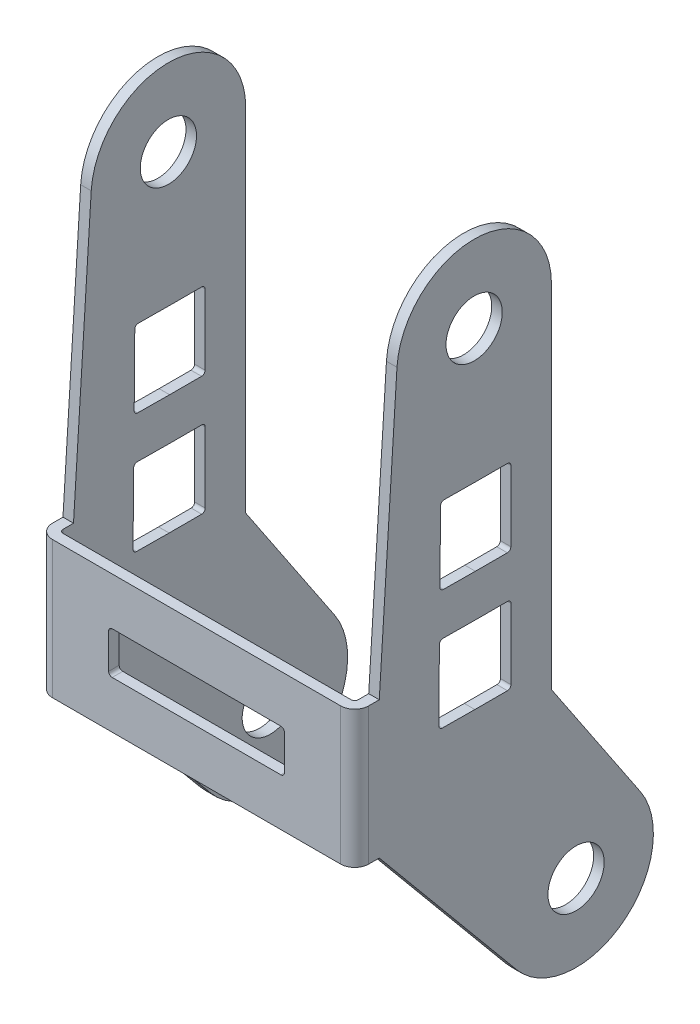
from build123d import *

# Parameters (mm, degrees)
BOSS_EXTRUDE1_DEPTH          = 1.5
SKETCH2_W                    = 43.5
SKETCH2_H                    = 19.5
BOSS_EXTRUDE2_DEPTH          = 3.5
SKETCH3_W                    = 42
SKETCH3_H                    = 19.5
CUT_EXTRUDE1_DEPTH           = 2
BOSS_EXTRUDE3_DEPTH          = 1.5
F_8_0_8_DIAMETER_HOLE1_D     = 8
F_8_0_8_DIAMETER_HOLE1_DEPTH = 1.5
F_8_0_8_DIAMETER_HOLE2_D     = 8
F_8_0_8_DIAMETER_HOLE2_DEPTH = 1.5
FILLET1_R                    = 0.5
FILLET2_R                    = 2
SKETCH9_W                    = 25
SKETCH9_H                    = 6
CUT_EXTRUDE2_DEPTH           = 1.5
FILLET3_R                    = 0.5
CUT_EXTRUDE3_DEPTH           = 45
FILLET4_R                    = 0.5


with BuildPart() as part:
    # Sketch1 → Boss-Extrude1 (new body)
    with BuildSketch(Plane(origin=(-22.5, 0, 0), x_dir=(0, -1, 0), z_dir=(-1, 0, 0))):
        with BuildLine():
            Line((82.02741971, -6.037413385), (58.5, 13.5))
            Line((58.5, 13.5), (39, 13.5))
            Line((39, 13.5), (-0.697466415, 10.97786594))
            ThreePointArc((-0.697466415, 10.97786594), (-10.994465093, -0.348908769), (0, -11))
            Line((0, -11), (50, -11))
            Line((50, -11), (68.880323706, -23.640544954))
            ThreePointArc((68.880323706, -23.640544954), (83.813260452, -21.082282295), (82.02741971, -6.037413385))
        make_face()
    extrude(amount=-BOSS_EXTRUDE1_DEPTH)

    # Sketch2 → Boss-Extrude2 (add)
    with BuildSketch(Plane.XY.offset(13.5)):
        with Locations((-0.75, -48.75)):
            Rectangle(SKETCH2_W, SKETCH2_H)
    extrude(amount=BOSS_EXTRUDE2_DEPTH)

    # Sketch3 → Cut-Extrude1 (cut)
    with BuildSketch(Plane(origin=(0, 0, 13.5), x_dir=(-1, 0, 0), z_dir=(0, 0, -1))):
        with Locations((0, -48.75)):
            Rectangle(SKETCH3_W, SKETCH3_H)
    extrude(amount=-CUT_EXTRUDE1_DEPTH, mode=Mode.SUBTRACT)

    # Sketch4 → Boss-Extrude3 (add)
    with BuildSketch(Plane(origin=(21, 0, 0), x_dir=(0, 0, -1), z_dir=(1, 0, 0))):
        with BuildLine():
            Line((11, 0), (11, -50))
            Line((11, -50), (23.640544954, -68.880323706))
            ThreePointArc((23.640544954, -68.880323706), (21.082282295, -83.813260452), (6.037413385, -82.02741971))
            Line((6.037413385, -82.02741971), (-13.5, -58.5))
            Line((-13.5, -58.5), (-17, -58.5))
            Line((-17, -58.5), (-17, -39))
            Line((-17, -39), (-13.5, -39))
            Line((-13.5, -39), (-10.97786594, 0.697466415))
            ThreePointArc((-10.97786594, 0.697466415), (0.348908769, 10.994465093), (11, 0))
        make_face()
    extrude(amount=BOSS_EXTRUDE3_DEPTH)

    # Ø8.0 (8) Diameter Hole1
    with Locations(Plane.ZY.offset(-21)):
        with Locations((-14.5, -75), (0, 0)):
            Hole(F_8_0_8_DIAMETER_HOLE1_D / 2, depth=F_8_0_8_DIAMETER_HOLE1_DEPTH)

    # Ø8.0 (8) Diameter Hole2
    with Locations(Plane(origin=(-21, 0, 0), x_dir=(0, 0, -1), z_dir=(1, 0, 0))):
        with Locations((14.5, -75), (0, 0)):
            Hole(F_8_0_8_DIAMETER_HOLE2_D / 2, depth=F_8_0_8_DIAMETER_HOLE2_DEPTH)

    # Fillet1
    fillet1_edges = [part.edges().sort_by_distance(p)[0] for p in [
        (21, -48.75, 15.5),
        (-21, -48.75, 15.5),
    ]]
    fillet(fillet1_edges, radius=FILLET1_R)

    # Fillet2
    fillet2_edges = [part.edges().sort_by_distance(p)[0] for p in [
        (-22.5, -48.75, 17),
        (22.5, -48.75, 17),
    ]]
    fillet(fillet2_edges, radius=FILLET2_R)

    # Sketch9 → Cut-Extrude2 (cut)
    with BuildSketch(Plane.XY.offset(17)):
        with Locations((0, -48.75)):
            Rectangle(SKETCH9_W, SKETCH9_H)
    extrude(amount=-CUT_EXTRUDE2_DEPTH, mode=Mode.SUBTRACT)

    # Fillet3
    fillet3_edges = [part.edges().sort_by_distance(p)[0] for p in [
        (12.5, -51.75, 16.25),
        (-12.5, -51.75, 16.25),
        (-12.5, -45.75, 16.25),
        (12.5, -45.75, 16.25),
    ]]
    fillet(fillet3_edges, radius=FILLET3_R)

    # Sketch11 → Cut-Extrude3 (cut)
    with BuildSketch(Plane.ZY.offset(22.5)):
        Polygon((-0.103461549, -47.005534907), (5.033080081, -46.962059996), (4.939981079, -35.962453976), (-0.150011884, -36.005534907), (-5.240187158, -36.005534907), (-5.240187158, -47.005534907), align=None)
        Polygon((-0.22195331, -19.005534907), (-5.22195331, -19.005534907), (-5.22195331, -30.005534907), (-0.175402975, -30.005534907), (4.87096661, -29.962823198), (4.777867607, -18.963217179), align=None)
    extrude(amount=-CUT_EXTRUDE3_DEPTH, mode=Mode.SUBTRACT)

    # Fillet4
    fillet4_edges = [part.edges().sort_by_distance(p)[0] for p in [
        (-21.75, -36.005534907, -0.150011884),
        (-21.75, -35.962453976, 4.939981079),
        (-21.75, -46.962059996, 5.033080081),
        (-21.75, -47.005534907, -0.103461549),
        (-21.75, -47.005534907, -5.240187158),
        (-21.75, -36.005534907, -5.240187158),
        (21.75, -36.005534907, -0.150011884),
        (21.75, -35.962453976, 4.939981079),
        (21.75, -46.962059996, 5.033080081),
        (21.75, -47.005534907, -0.103461549),
        (21.75, -47.005534907, -5.240187158),
        (21.75, -36.005534907, -5.240187158),
        (-21.75, -19.005534907, -0.22195331),
        (-21.75, -18.963217179, 4.777867607),
        (-21.75, -29.962823198, 4.87096661),
        (-21.75, -30.005534907, -0.175402975),
        (-21.75, -30.005534907, -5.22195331),
        (-21.75, -19.005534907, -5.22195331),
        (21.75, -19.005534907, -0.22195331),
        (21.75, -18.963217179, 4.777867607),
        (21.75, -29.962823198, 4.87096661),
        (21.75, -30.005534907, -0.175402975),
        (21.75, -30.005534907, -5.22195331),
        (21.75, -19.005534907, -5.22195331),
    ]]
    fillet(fillet4_edges, radius=FILLET4_R)


solid = part.part
